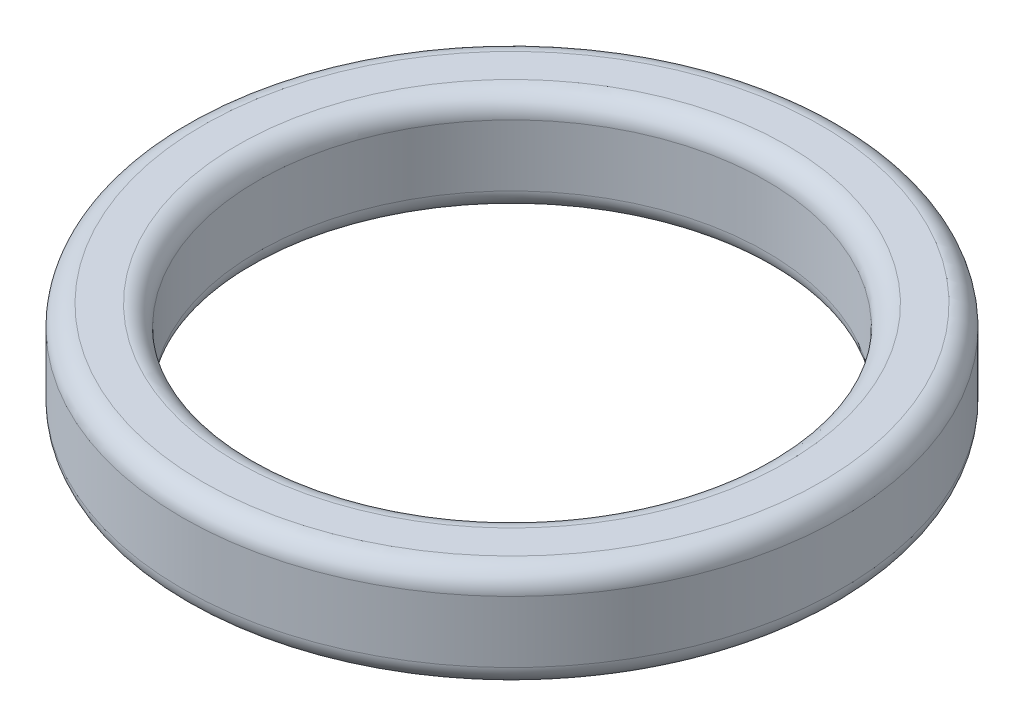
from build123d import *

# Parameters (mm, degrees)
SKETCH1_R      = 32.122013297
SKETCH1_R_2    = 24.775693006
EXTRUDE1_DEPTH = 10
FILLET1_R      = 2


with BuildPart() as part:
    # Sketch1 → Extrude1 (new body)
    with BuildSketch(Plane(origin=(0, 0, 0), x_dir=(1, 0, 0), z_dir=(0, 1, 0))):
        Circle(SKETCH1_R)
        Circle(SKETCH1_R_2, mode=Mode.SUBTRACT)
    extrude(amount=EXTRUDE1_DEPTH)

    # Fillet1
    fillet1_edges = [part.edges().sort_by_distance(p)[0] for p in [
        (-32.122013297, 0, 0),
        (-32.122013297, 10, 0),
        (-24.775693006, 0, 0),
        (-24.775693006, 10, 0),
    ]]
    fillet(fillet1_edges, radius=FILLET1_R)


solid = part.part
